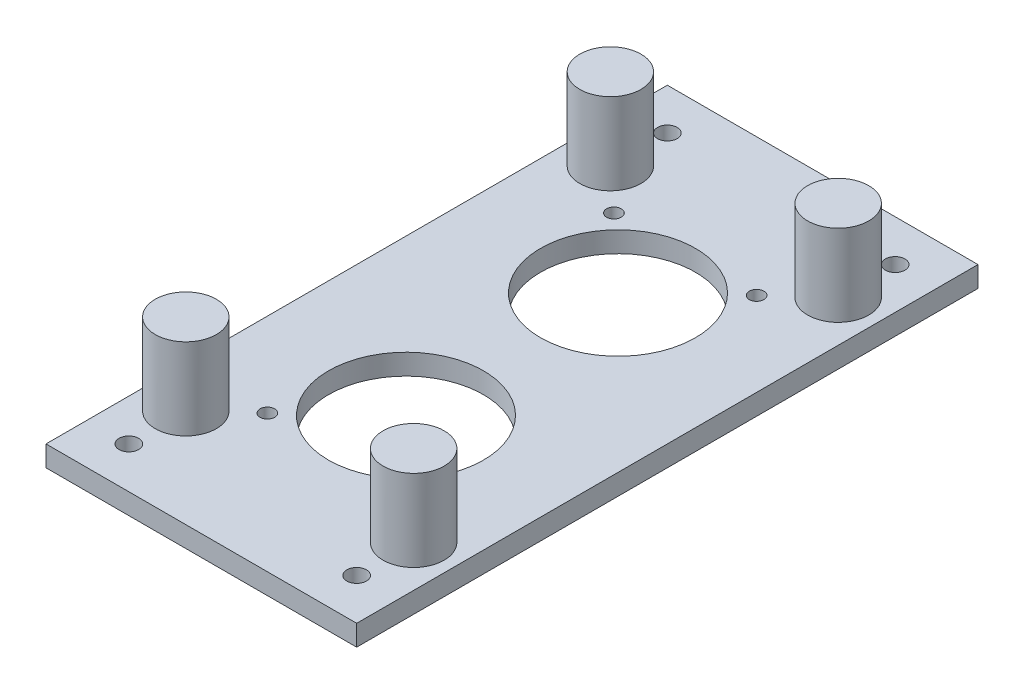
from build123d import *

# Parameters (mm, degrees)
SKETCH1_W              = 38.1
SKETCH1_H              = 76.2
BOSS_EXTRUDE1_DEPTH    = 2.54
F_1_0MM_DOWEL_HOLE1_D  = 19
M1_6_CLEARANCE_HOLE1_D = 1.8
M2_CLEARANCE_HOLE4_D   = 2.4
SKETCH15_R             = 3.749999993
BOSS_EXTRUDE2_DEPTH    = 10.000000066


with BuildPart() as part:
    # Sketch1 → Boss-Extrude1 (new body)
    with BuildSketch(Plane(origin=(0, 0, 0), x_dir=(1, 0, 0), z_dir=(0, 1, 0))):
        Rectangle(SKETCH1_W, SKETCH1_H)
    extrude(amount=BOSS_EXTRUDE1_DEPTH)

    # Ø1.0mm Dowel Hole1 (through all)
    with Locations(Plane(origin=(0, 2.54, 0), x_dir=(1, 0, 0), z_dir=(0, 1, 0))):
        with Locations((0, -13.000000035), (0, 13.000000035)):
            Hole(F_1_0MM_DOWEL_HOLE1_D / 2)

    # M1.6 Clearance Hole1 (through all)
    with Locations(Plane(origin=(0, 2.54, 0), x_dir=(1, 0, 0), z_dir=(0, 1, 0))):
        with Locations((8.750000026, 21.250000045), (8.750000026, -21.250000045), (-8.750000026, -21.250000045), (-8.750000026, 21.250000045)):
            Hole(M1_6_CLEARANCE_HOLE1_D / 2)

    # M2 Clearance Hole4 (through all)
    with Locations(Plane(origin=(0, 2.54, 0), x_dir=(1, 0, 0), z_dir=(0, 1, 0))):
        with Locations((-13.97, 33.02), (13.97, 33.02), (-13.97, -33.02), (13.97, -33.02)):
            Hole(M2_CLEARANCE_HOLE4_D / 2)

    # Sketch15 → Boss-Extrude2 (add)
    with BuildSketch(Plane(origin=(0, 2.54, 0), x_dir=(1, 0, 0), z_dir=(0, 1, 0))):
        with Locations((-13.97, -26.035)):
            Circle(SKETCH15_R)
        with Locations((13.97, -26.035)):
            Circle(SKETCH15_R)
    boss_extrude2 = extrude(amount=BOSS_EXTRUDE2_DEPTH)

    # Mirror1: Boss-Extrude2 across plane
    add(boss_extrude2.mirror(Plane.XY))


solid = part.part
